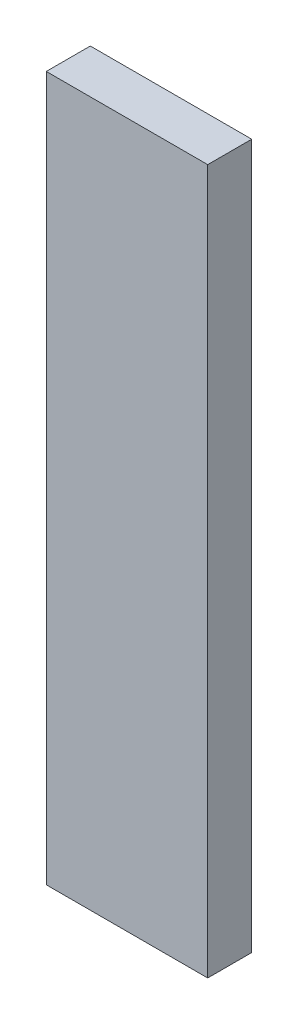
from build123d import *

# Parameters (mm, degrees)
SKETCH1_W           = 139.7
SKETCH1_H           = 38.1
BOSS_EXTRUDE1_DEPTH = 609.6


with BuildPart() as part:
    # Sketch1 → Boss-Extrude1 (new body)
    with BuildSketch(Plane(origin=(0, 0, 0), x_dir=(1, 0, 0), z_dir=(0, 1, 0))):
        Rectangle(SKETCH1_W, SKETCH1_H)
    extrude(amount=BOSS_EXTRUDE1_DEPTH)


solid = part.part
